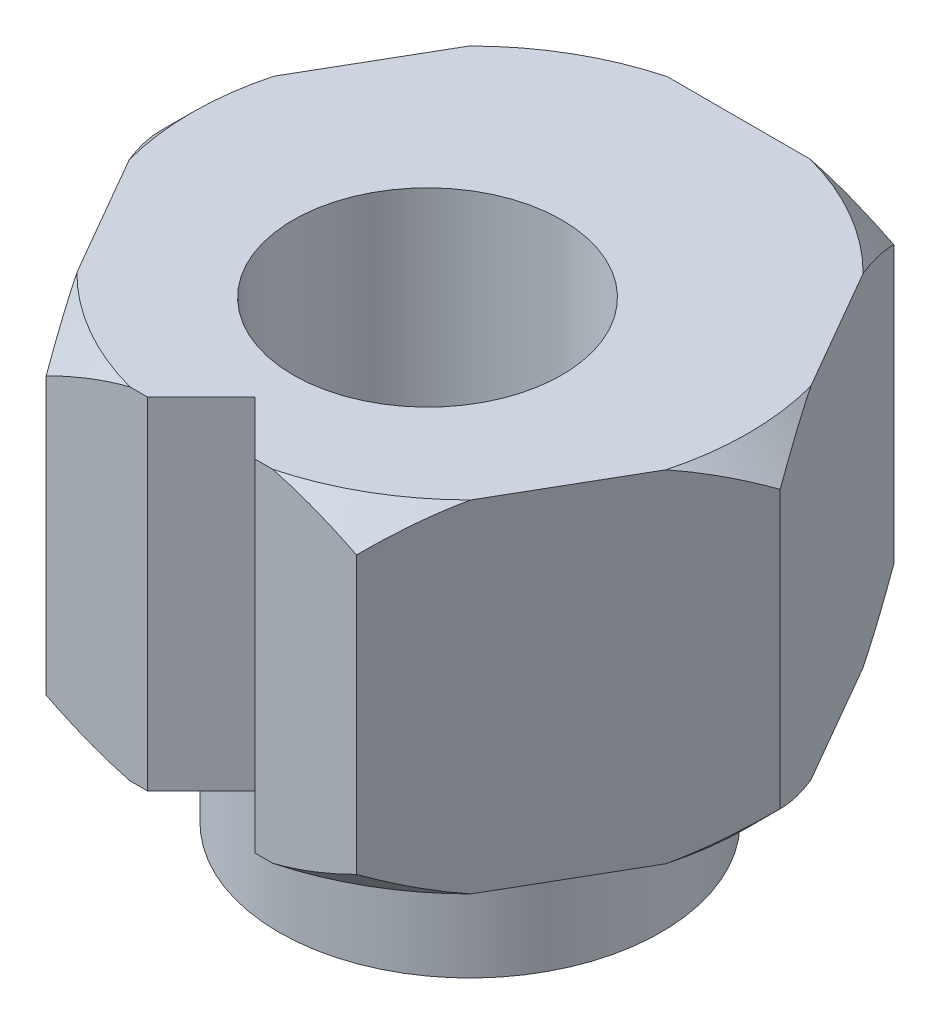
from build123d import *

# Parameters (mm, degrees)
BOSS_EXTRUDE1_DEPTH = 6.35
SKETCH3_R           = 3.555
BOSS_EXTRUDE3_DEPTH = 2.5
SKETCH4_R           = 2.5
CUT_EXTRUDE1_DEPTH  = 9.85
CUT_EXTRUDE2_DEPTH  = 7.35


with BuildPart() as part:
    # Sketch1 → Boss-Extrude1 (new body)
    with BuildSketch(Plane(origin=(0, 0, 0), x_dir=(1, 0, 0), z_dir=(0, 1, 0))):
        Polygon((5.773502692, 0), (2.886751346, 5), (-2.886751346, 5), (-5.773502692, 0), (-2.886751346, -5), (2.886751346, -5), align=None)
    extrude(amount=BOSS_EXTRUDE1_DEPTH)

    # Sketch3 → Boss-Extrude3 (add)
    with BuildSketch(Plane.XZ):
        Circle(SKETCH3_R)
    extrude(amount=BOSS_EXTRUDE3_DEPTH)

    # Sketch4 → Cut-Extrude1 (cut, through all)
    with BuildSketch(Plane(origin=(0, 6.35, 0), x_dir=(1, 0, 0), z_dir=(0, 1, 0))):
        with Locations((0, -0.79)):
            Circle(SKETCH4_R)
    extrude(amount=-CUT_EXTRUDE1_DEPTH, mode=Mode.SUBTRACT)

    # Sketch5 → Cut-Extrude2 (cut, through all)
    with BuildSketch(Plane(origin=(0, 0, 0), x_dir=(-1, 0, 0), z_dir=(0, -1, 0))):
        Polygon((-1, -5), (1, -5), (0, -4), align=None)
    extrude(amount=-CUT_EXTRUDE2_DEPTH, mode=Mode.SUBTRACT)

    # Sketch6 → Cut-Revolve1 (revolve, cut)
    with BuildSketch(Plane.XY):
        Polygon((5.173502692, 6.35), (5.773502692, 6.35), (5.773502692, 5.75), align=None)
        Polygon((5.773502692, 0.6), (5.173502692, 0), (5.773502692, 0), align=None)
    revolve(axis=Axis((0, 0, 0), (0, 1, 0)), mode=Mode.SUBTRACT)


solid = part.part
